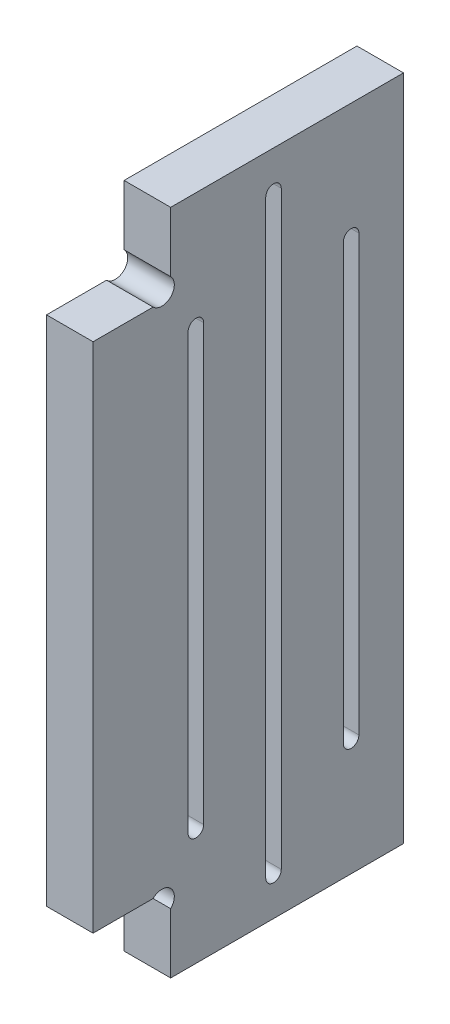
from build123d import *

# Parameters (mm, degrees)
EXTRUSION1_DEPTH        = 6
ENL_V_MAT_EXTRU_2_DEPTH = 7


with BuildPart() as part:
    # Esquisse1 → Extrusion1 (new body)
    with BuildSketch(Plane(origin=(0, 0, 0), x_dir=(0, 0, -1), z_dir=(1, 0, 0))):
        with BuildLine():
            Line((110, 226.862827305), (80, 226.862827305))
            Line((80, 226.862827305), (80, 219.125569005))
            ThreePointArc((80, 219.125569005), (80, 216.862827305), (77.7372583, 216.862827305))
            Line((77.7372583, 216.862827305), (70, 216.862827305))
            Line((70, 216.862827305), (70, 150.862827305))
            Line((70, 150.862827305), (77.7372583, 150.862827305))
            ThreePointArc((77.7372583, 150.862827305), (80, 150.862827305), (80, 148.600085605))
            Line((80, 148.600085605), (80, 140.862827305))
            Line((80, 140.862827305), (110, 140.862827305))
            Line((110, 140.862827305), (110, 226.862827305))
        make_face()
    extrude(amount=EXTRUSION1_DEPTH)

    # Esquisse3 → Enlèv. mat.-Extru.2 (cut, through all)
    with BuildSketch(Plane.ZY):
        with BuildLine():
            Line((-84.25, 155.862827305), (-84.25, 211.862827305))
            ThreePointArc((-84.25, 211.862827305), (-83.25, 212.862827305), (-82.25, 211.862827305))
            Line((-82.25, 211.862827305), (-82.25, 155.862827305))
            ThreePointArc((-82.25, 155.862827305), (-83.25, 154.862827305), (-84.25, 155.862827305))
        make_face()
        with BuildLine():
            Line((-94.25, 145.862827305), (-94.25, 221.862827305))
            ThreePointArc((-94.25, 221.862827305), (-93.25, 222.862827305), (-92.25, 221.862827305))
            Line((-92.25, 221.862827305), (-92.25, 145.862827305))
            ThreePointArc((-92.25, 145.862827305), (-93.25, 144.862827305), (-94.25, 145.862827305))
        make_face()
        with BuildLine():
            Line((-104.25, 155.862827305), (-104.25, 211.862827305))
            ThreePointArc((-104.25, 211.862827305), (-103.25, 212.862827305), (-102.25, 211.862827305))
            Line((-102.25, 211.862827305), (-102.25, 155.862827305))
            ThreePointArc((-102.25, 155.862827305), (-103.25, 154.862827305), (-104.25, 155.862827305))
        make_face()
    extrude(amount=-ENL_V_MAT_EXTRU_2_DEPTH, mode=Mode.SUBTRACT)


solid = part.part
